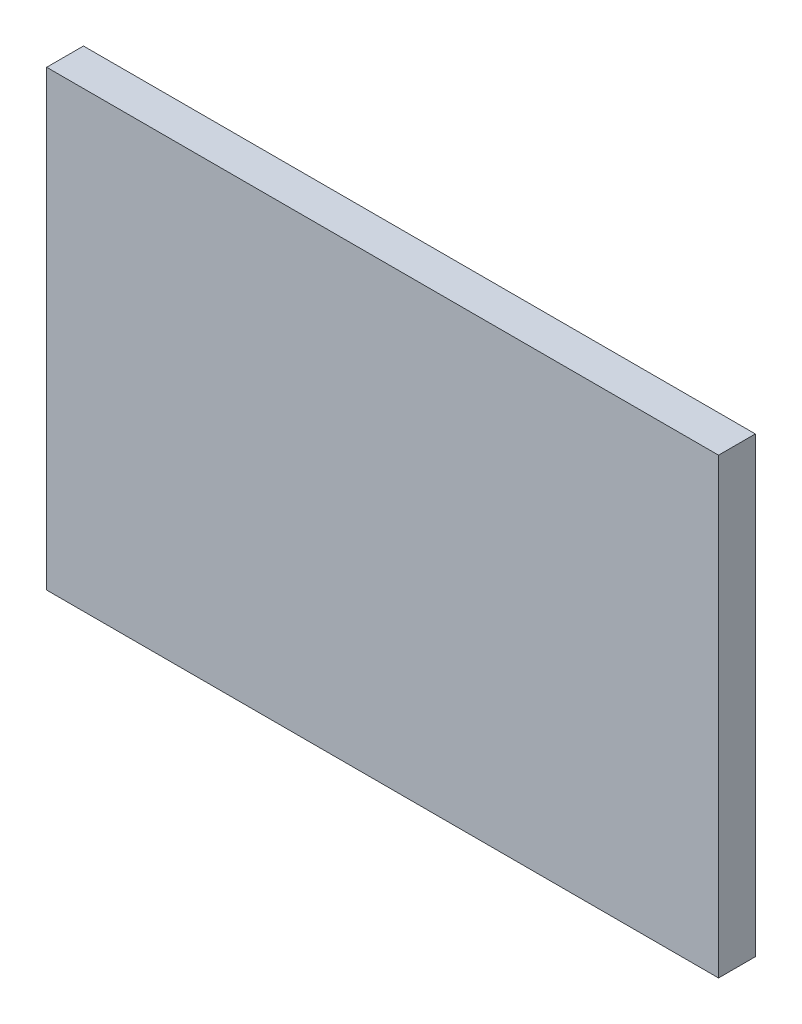
from build123d import *

# Parameters (mm, degrees)
SKETCH1_W           = 29.21
SKETCH1_H           = 19.685
BOSS_EXTRUDE1_DEPTH = 1.6


with BuildPart() as part:
    # Sketch1 → Boss-Extrude1 (new body)
    with BuildSketch(Plane.XY):
        Rectangle(SKETCH1_W, SKETCH1_H)
    extrude(amount=BOSS_EXTRUDE1_DEPTH)


solid = part.part
